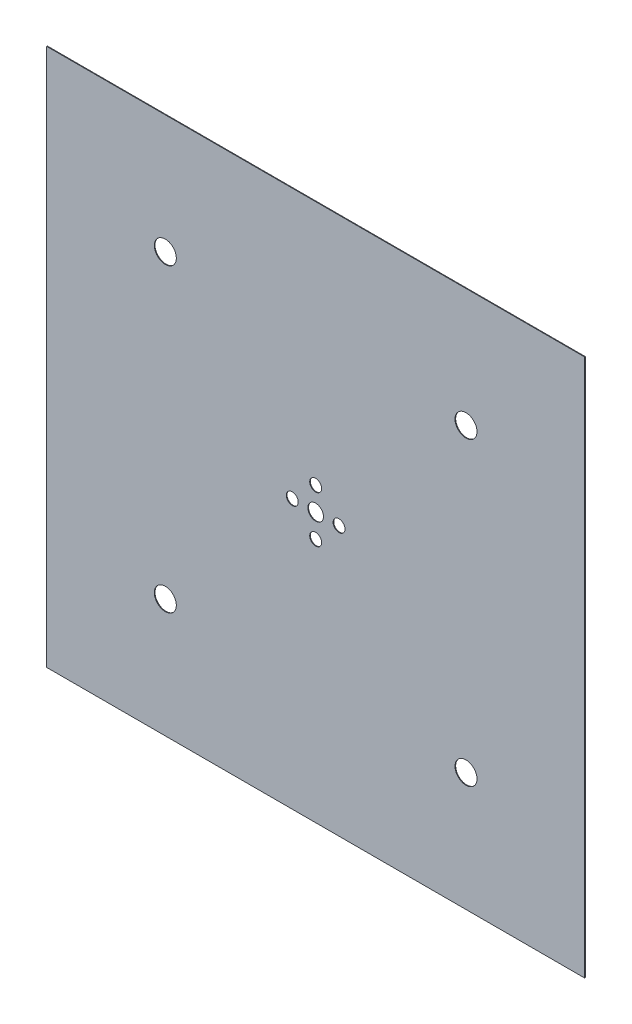
from build123d import *

# Parameters (mm, degrees)
SKETCH2_W           = 3220
SKETCH2_H           = 3220
SKETCH2_R           = 46.75
SKETCH2_R_2         = 35.6375
SKETCH2_R_3         = 65.8
BOSS_EXTRUDE1_DEPTH = 4


with BuildPart() as part:
    # Sketch2 → Boss-Extrude1 (new body)
    with BuildSketch(Plane.XY):
        Rectangle(SKETCH2_W, SKETCH2_H)
        Circle(SKETCH2_R, mode=Mode.SUBTRACT)
        with Locations((0, 140)):
            Circle(SKETCH2_R_2, mode=Mode.SUBTRACT)
        with Locations((-900, 900)):
            Circle(SKETCH2_R_3, mode=Mode.SUBTRACT)
        with Locations((0, -140)):
            Circle(SKETCH2_R_2, mode=Mode.SUBTRACT)
        with Locations((-900, -900)):
            Circle(SKETCH2_R_3, mode=Mode.SUBTRACT)
        with Locations((140, 0)):
            Circle(SKETCH2_R_2, mode=Mode.SUBTRACT)
        with Locations((-140, 0)):
            Circle(SKETCH2_R_2, mode=Mode.SUBTRACT)
        with Locations((900, -900)):
            Circle(SKETCH2_R_3, mode=Mode.SUBTRACT)
        with Locations((900, 900)):
            Circle(SKETCH2_R_3, mode=Mode.SUBTRACT)
    extrude(amount=BOSS_EXTRUDE1_DEPTH)


solid = part.part
